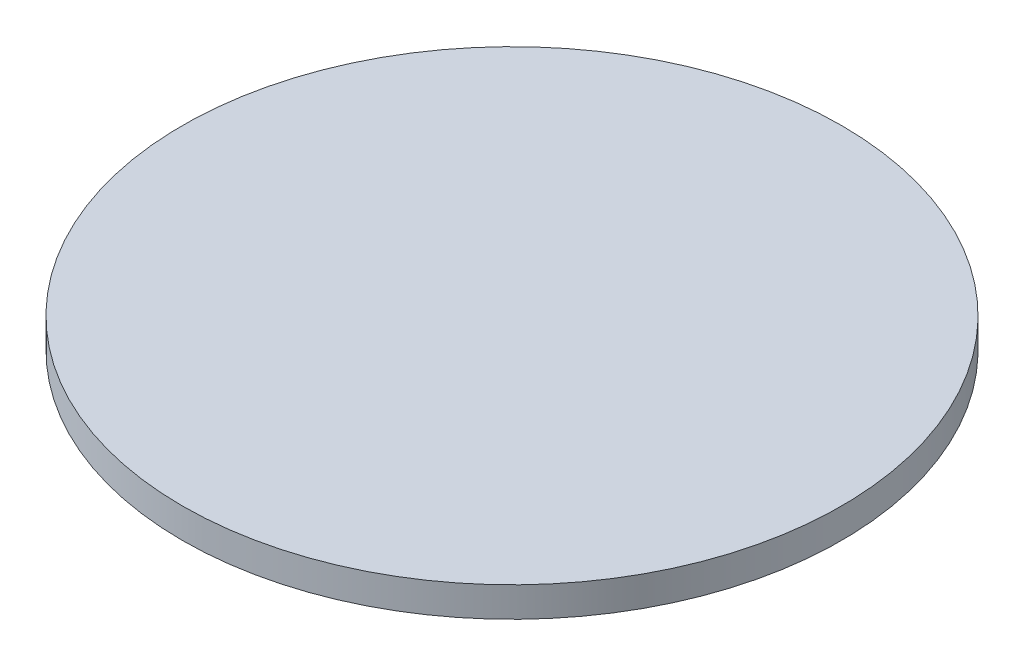
from build123d import *

# Parameters (mm, degrees)
SKETCH1_R           = 35
BOSS_EXTRUDE3_DEPTH = 3.175


with BuildPart() as part:
    # Sketch1 → Boss-Extrude3 (new body)
    with BuildSketch(Plane(origin=(0, 0, 0), x_dir=(1, 0, 0), z_dir=(0, 1, 0))):
        Circle(SKETCH1_R)
    extrude(amount=BOSS_EXTRUDE3_DEPTH)


solid = part.part
